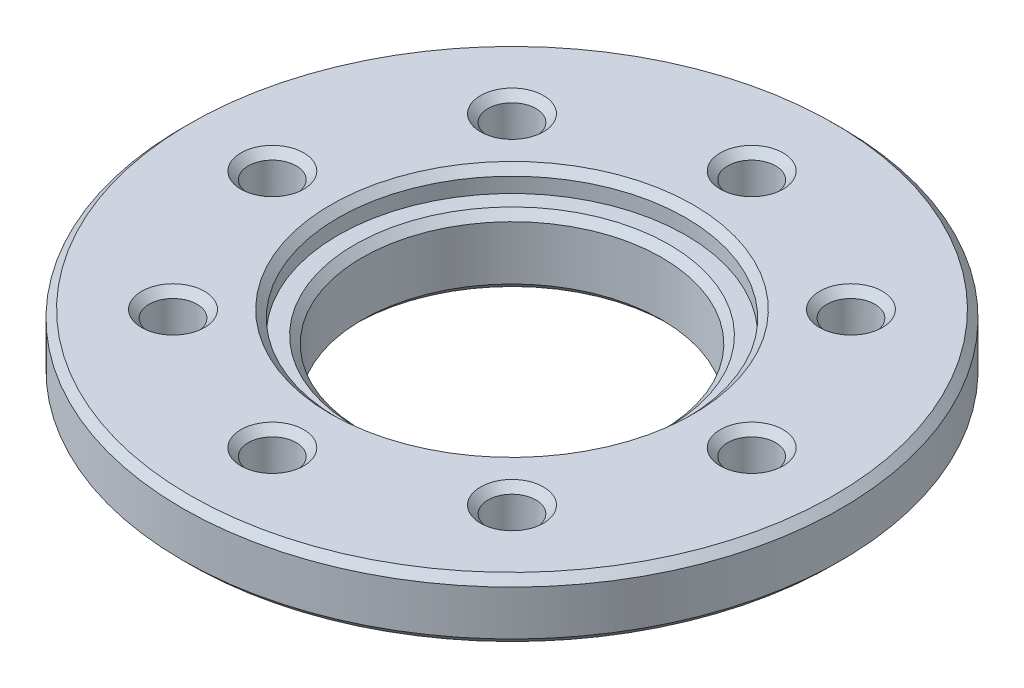
from build123d import *

# Parameters (mm, degrees)
SKETCH1_W                                            = 11
SKETCH1_H                                            = 2
SKETCH2_R                                            = 6.25
BOSS_EXTRUDE1_DEPTH                                  = 1.05
HOLE1_D                                              = 1.6
HOLE1_DEPTH                                          = 3.05
CBORE_FOR_3_8_BINDING_HEAD_MACHINE_SCREW_D           = 10
CBORE_FOR_3_8_BINDING_HEAD_MACHINE_SCREW_DEPTH       = 3.05
CBORE_FOR_3_8_BINDING_HEAD_MACHINE_SCREW_CBORE_D     = 11.6
CBORE_FOR_3_8_BINDING_HEAD_MACHINE_SCREW_CBORE_DEPTH = 0.75
CHAMFER1_SIZE                                        = 0.25


with BuildPart() as part:
    # Sketch1 → Revolve1 (revolve)
    with BuildSketch(Plane.XY):
        with Locations((5.5, -1)):
            Rectangle(SKETCH1_W, SKETCH1_H)
    revolve(axis=Axis((0, 0, 0), (0, -1, 0)))

    # Sketch2 → Boss-Extrude1 (add)
    with BuildSketch(Plane.XZ.offset(2)):
        Circle(SKETCH2_R)
    extrude(amount=BOSS_EXTRUDE1_DEPTH)

    # Hole1
    with Locations(Plane(origin=(0, 0, 0), x_dir=(1, 0, 0), z_dir=(0, 1, 0))):
        with Locations((0, 8), (5.656854249, 5.656854249), (8, 0), (5.656854249, -5.656854249), (0, -8), (-5.656854249, -5.656854249), (-8, 0), (-5.656854249, 5.656854249)):
            Hole(HOLE1_D / 2, depth=HOLE1_DEPTH)

    # CBORE for 3/8 Binding Head Machine Screw1
    with Locations(Plane(origin=(0, 0, 0), x_dir=(1, 0, 0), z_dir=(0, 1, 0))):
        with Locations((0, 0)):
            CounterBoreHole(CBORE_FOR_3_8_BINDING_HEAD_MACHINE_SCREW_D / 2, CBORE_FOR_3_8_BINDING_HEAD_MACHINE_SCREW_CBORE_D / 2, CBORE_FOR_3_8_BINDING_HEAD_MACHINE_SCREW_CBORE_DEPTH, depth=CBORE_FOR_3_8_BINDING_HEAD_MACHINE_SCREW_DEPTH)

    # Chamfer1
    chamfer1_edges = [part.edges().sort_by_distance(p)[0] for p in [
        (-4.856854249, 0, -5.656854249),
        (-7.2, 0, 0),
        (-4.856854249, 0, 5.656854249),
        (-11, -2, 0),
        (0.8, 0, 8),
        (6.456854249, 0, 5.656854249),
        (-11, 0, 0),
        (8.8, 0, 0),
        (6.456854249, 0, -5.656854249),
        (0.8, 0, -8),
        (-5.8, 0, 0),
        (5, -3.05, 0),
        (5, -0.75, 0),
        (-6.25, -3.05, 0),
    ]]
    chamfer(chamfer1_edges, length=CHAMFER1_SIZE)


solid = part.part
